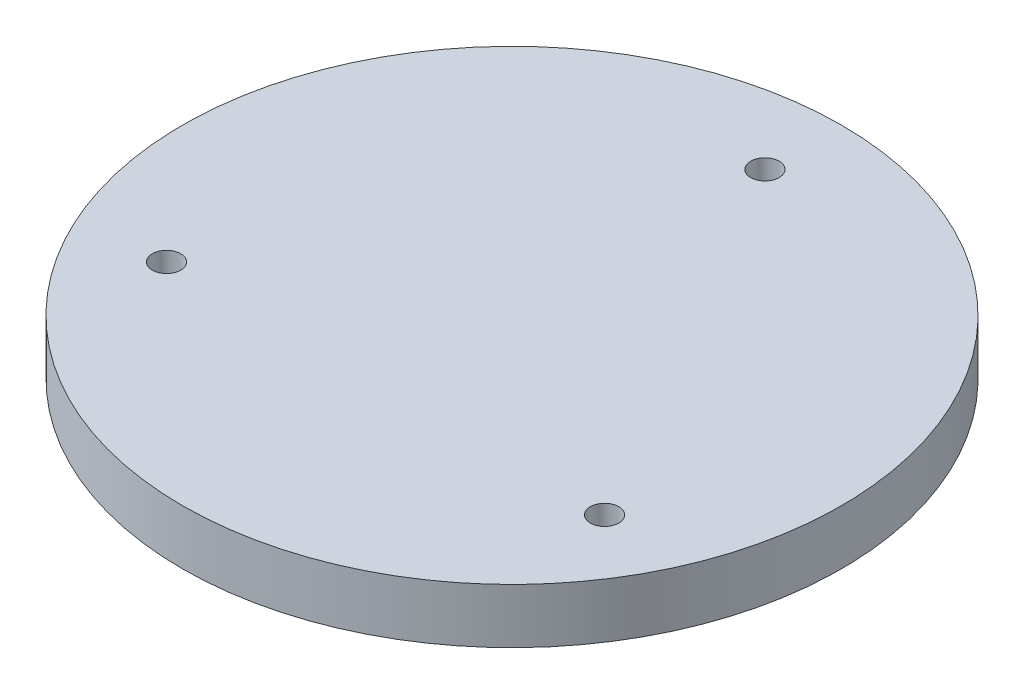
from build123d import *

# Parameters (mm, degrees)
SKETCH1_R           = 38.227
BOSS_EXTRUDE1_DEPTH = 6.35
SKETCH2_R           = 1.651
CUT_EXTRUDE1_DEPTH  = 55.43279855


with BuildPart() as part:
    # Sketch1 → Boss-Extrude1 (new body)
    with BuildSketch(Plane(origin=(0, 0, 0), x_dir=(1, 0, 0), z_dir=(0, 1, 0))):
        Circle(SKETCH1_R)
    extrude(amount=BOSS_EXTRUDE1_DEPTH)

    # Sketch2 → Cut-Extrude1 (cut, through all)
    with BuildSketch(Plane(origin=(0, 6.35, 0), x_dir=(1, 0, 0), z_dir=(0, 1, 0))):
        with Locations((0, 29.337)):
            Circle(SKETCH2_R)
        with Locations((25.406587271, -14.6685)):
            Circle(SKETCH2_R)
        with Locations((-25.406587271, -14.6685)):
            Circle(SKETCH2_R)
    extrude(amount=-CUT_EXTRUDE1_DEPTH, mode=Mode.SUBTRACT)


solid = part.part
